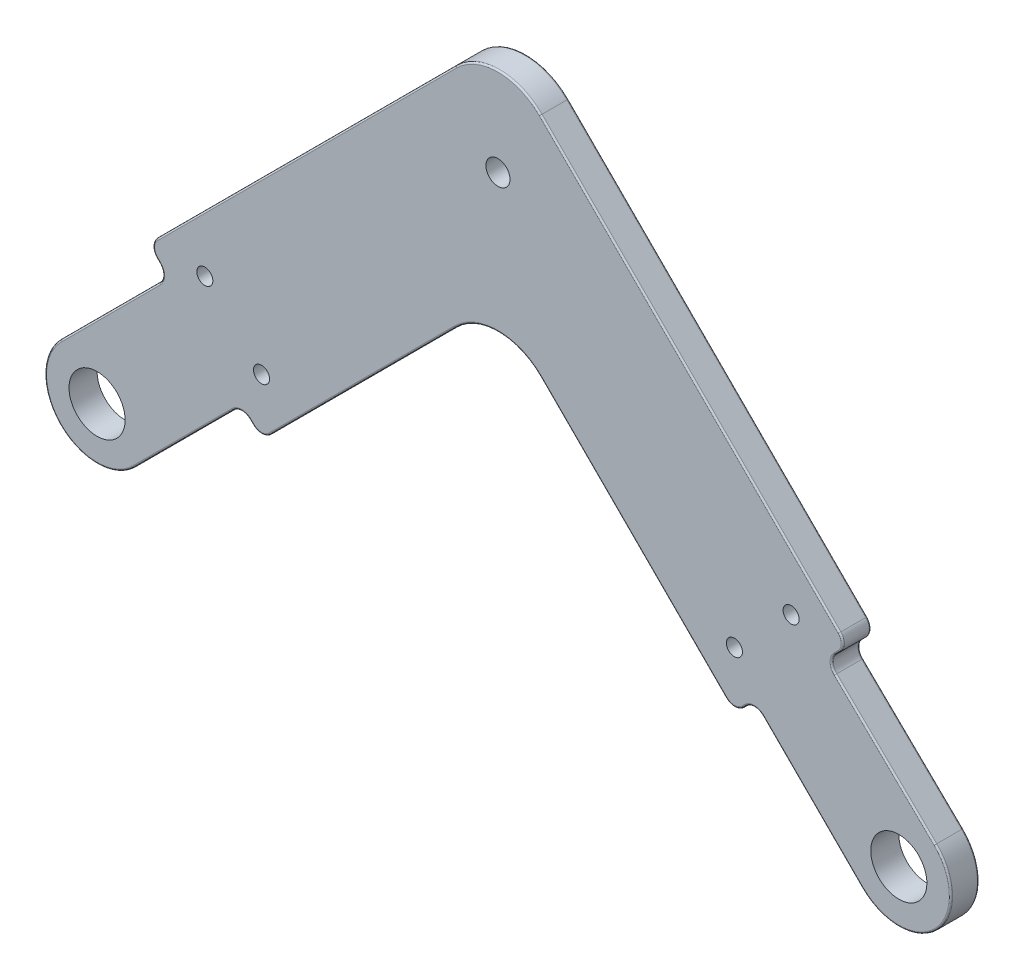
from build123d import *

# Parameters (mm, degrees)
SKETCH3_R           = 3.5
SKETCH3_R_2         = 1
SKETCH3_R_3         = 1.5
BOSS_EXTRUDE1_DEPTH = 3.5
FILLET1_R           = 7.5
FILLET2_R           = 1.5
FILLET3_R           = 0.2


with BuildPart() as part:
    # Sketch3 → Boss-Extrude1 (new body)
    with BuildSketch(Plane.XY):
        with BuildLine():
            Line((-79.493903346, 6.363961031), (-50, 35.857864376))
            Line((-50, 35.857864376), (-20.506096654, 6.363961031))
            Line((-20.506096654, 6.363961031), (-18.03122292, 8.838834765))
            Line((-18.03122292, 8.838834765), (-4.596194078, -4.596194078))
            ThreePointArc((-4.596194078, -4.596194078), (4.627002282, -4.565177968), (4.533955357, 4.657601188))
            Line((4.533955357, 4.657601188), (-9.019148409, 17.850909276))
            Line((-9.019148409, 17.850909276), (-6.363961031, 20.506096654))
            Line((-6.363961031, 20.506096654), (-50, 64.142135624))
            Line((-50, 64.142135624), (-93.636038969, 20.506096654))
            Line((-93.636038969, 20.506096654), (-91.161165235, 18.03122292))
            Line((-91.161165235, 18.03122292), (-104.596194078, 4.596194078))
            ThreePointArc((-104.596194078, 4.596194078), (-104.596194078, -4.596194078), (-95.403805922, -4.596194078))
            Line((-95.403805922, -4.596194078), (-81.96877708, 8.838834765))
            Line((-81.96877708, 8.838834765), (-79.493903346, 6.363961031))
        make_face()
        with Locations((-100, 0)):
            Circle(SKETCH3_R, mode=Mode.SUBTRACT)
        Circle(SKETCH3_R, mode=Mode.SUBTRACT)
        with Locations((-86.561577384, 20.509490428)):
            Circle(SKETCH3_R_2, mode=Mode.SUBTRACT)
        with Locations((-79.490509572, 13.438422616)):
            Circle(SKETCH3_R_2, mode=Mode.SUBTRACT)
        with Locations((-20.509490428, 13.438422616)):
            Circle(SKETCH3_R_2, mode=Mode.SUBTRACT)
        with Locations((-13.438422616, 20.509490428)):
            Circle(SKETCH3_R_2, mode=Mode.SUBTRACT)
        with Locations((-50, 50)):
            Circle(SKETCH3_R_3, mode=Mode.SUBTRACT)
    extrude(amount=BOSS_EXTRUDE1_DEPTH)

    # Fillet1
    fillet1_edges = [part.edges().sort_by_distance(p)[0] for p in [
        (-50, 64.142135624, 1.75),
        (-50, 35.857864376, 1.75),
    ]]
    fillet(fillet1_edges, radius=FILLET1_R)

    # Fillet2
    fillet2_edges = [part.edges().sort_by_distance(p)[0] for p in [
        (-91.161165235, 18.03122292, 1.75),
        (-93.636038969, 20.506096654, 1.75),
        (-6.363961031, 20.506096654, 1.75),
        (-9.019148409, 17.850909276, 1.75),
        (-18.03122292, 8.838834765, 1.75),
        (-20.506096654, 6.363961031, 1.75),
        (-79.493903346, 6.363961031, 1.75),
        (-81.96877708, 8.838834765, 1.75),
    ]]
    fillet(fillet2_edges, radius=FILLET2_R)

    # Fillet3
    fillet3_edges = [part.edges().sort_by_distance(p)[0] for p in [
        (-18.03122292, 8.217514421, 0),
        (-18.03122292, 8.217514421, 3.5),
        (-8.383430059, 17.855184959, 0),
        (-8.383430059, 17.855184959, 3.5),
        (-81.96877708, 8.217514421, 0),
        (-81.96877708, 8.217514421, 3.5),
        (-91.782485579, 18.03122292, 0),
        (-91.782485579, 18.03122292, 3.5),
        (4.627002282, -4.565177968, 0),
        (-104.596194078, -4.596194078, 0),
        (-104.596194078, -4.596194078, 3.5),
        (-33.131727984, 18.98959236, 0),
        (-33.131727984, 18.98959236, 3.5),
        (-26.060660172, 40.202795796, 0),
        (-50, 61.035533906, 0),
        (-26.060660172, 40.202795796, 3.5),
        (-50, 61.035533906, 3.5),
        (-50, 32.751262658, 0),
        (-50, 32.751262658, 3.5),
        (-10.783378413, 1.590990258, 0),
        (-10.783378413, 1.590990258, 3.5),
        (-19.268659787, 7.601397898, 0),
        (-19.268659787, 7.601397898, 3.5),
        (-73.939339828, 40.202795796, 0),
        (-7.684372679, 19.185685006, 0),
        (-1.697903009, 10.724021751, 0),
        (-66.868272016, 18.98959236, 0),
        (-80.731340213, 7.601397898, 0),
        (-89.216621587, 1.590990258, 0),
        (-98.409009742, 10.783378413, 0),
        (-92.398602102, 19.268659787, 0),
        (-93.014718626, 20.506096654, 0),
        (-79.493903346, 6.985281374, 0),
        (4.627002282, -4.565177968, 3.5),
        (-6.985281374, 20.506096654, 0),
        (-20.506096654, 6.985281374, 0),
        (-73.939339828, 40.202795796, 3.5),
        (-92.398602102, 19.268659787, 3.5),
        (-98.409009742, 10.783378413, 3.5),
        (-89.216621587, 1.590990258, 3.5),
        (-80.731340213, 7.601397898, 3.5),
        (-66.868272016, 18.98959236, 3.5),
        (-1.697903009, 10.724021751, 3.5),
        (-7.684372679, 19.185685006, 3.5),
        (-93.014718626, 20.506096654, 3.5),
        (-79.493903346, 6.985281374, 3.5),
        (-6.985281374, 20.506096654, 3.5),
        (-20.506096654, 6.985281374, 3.5),
    ]]
    fillet(fillet3_edges, radius=FILLET3_R)


solid = part.part
